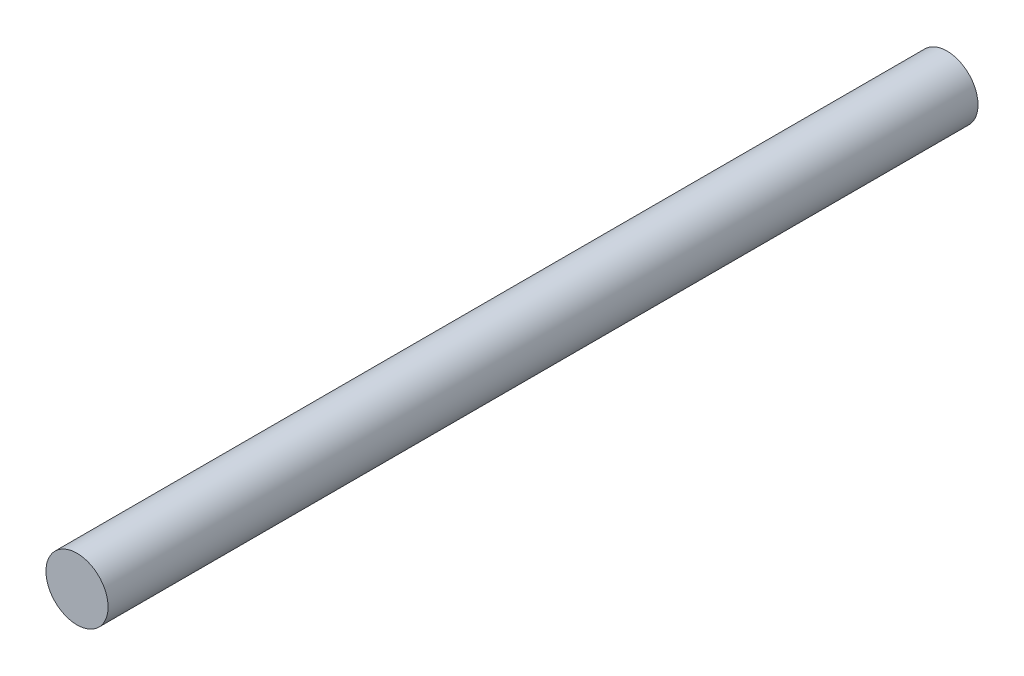
from build123d import *

# Parameters (mm, degrees)
SKETCH1_R           = 6.35
EXTRUDE1_DEPTH      = 88.9
EXTRUDE1_DEPTH_BACK = 88.9


with BuildPart() as part:
    # Sketch1 → Extrude1 (new body, two sides)
    with BuildSketch(Plane.XY) as extrude1_sk:
        Circle(SKETCH1_R)
    extrude(amount=EXTRUDE1_DEPTH)
    extrude(extrude1_sk.sketch, amount=-EXTRUDE1_DEPTH_BACK)


solid = part.part
